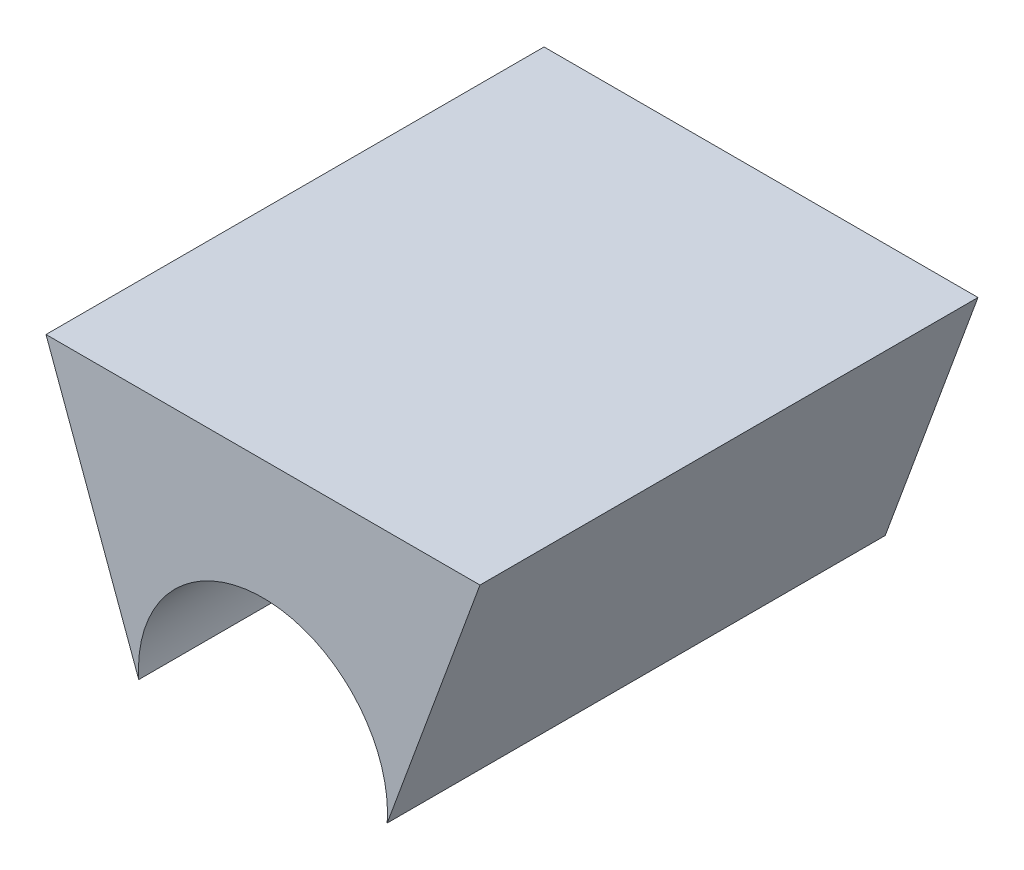
from build123d import *

# Parameters (mm, degrees)
BOSS_EXTRUDE1_DEPTH = 10
SKETCH2_R           = 2.5
CUT_EXTRUDE1_DEPTH  = 11


with BuildPart() as part:
    # Sketch1 → Boss-Extrude1 (new body)
    with BuildSketch(Plane.XY):
        with BuildLine():
            Line((-4.35673336, 4.9), (-2.252817149, -0.827535434))
            ThreePointArc((-2.252817149, -0.827535434), (0, -2.4), (2.252817149, -0.827535434))
            Line((2.252817149, -0.827535434), (4.35673336, 4.9))
            Line((4.35673336, 4.9), (-4.35673336, 4.9))
        make_face()
    extrude(amount=BOSS_EXTRUDE1_DEPTH)

    # Sketch2 → Cut-Extrude1 (cut, through all)
    with BuildSketch(Plane.XY.offset(10)):
        Circle(SKETCH2_R)
    extrude(amount=-CUT_EXTRUDE1_DEPTH, mode=Mode.SUBTRACT)


solid = part.part
